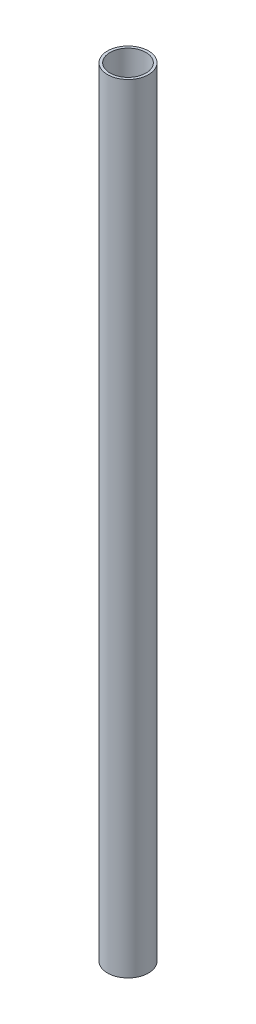
from build123d import *

# Parameters (mm, degrees)
SKETCH1_R      = 9.525
SKETCH1_R_2    = 8.325
EXTRUDE1_DEPTH = 361


with BuildPart() as part:
    # Sketch1 → Extrude1 (new body)
    with BuildSketch(Plane.XZ):
        Circle(SKETCH1_R)
        Circle(SKETCH1_R_2, mode=Mode.SUBTRACT)
    extrude(amount=EXTRUDE1_DEPTH)


solid = part.part
